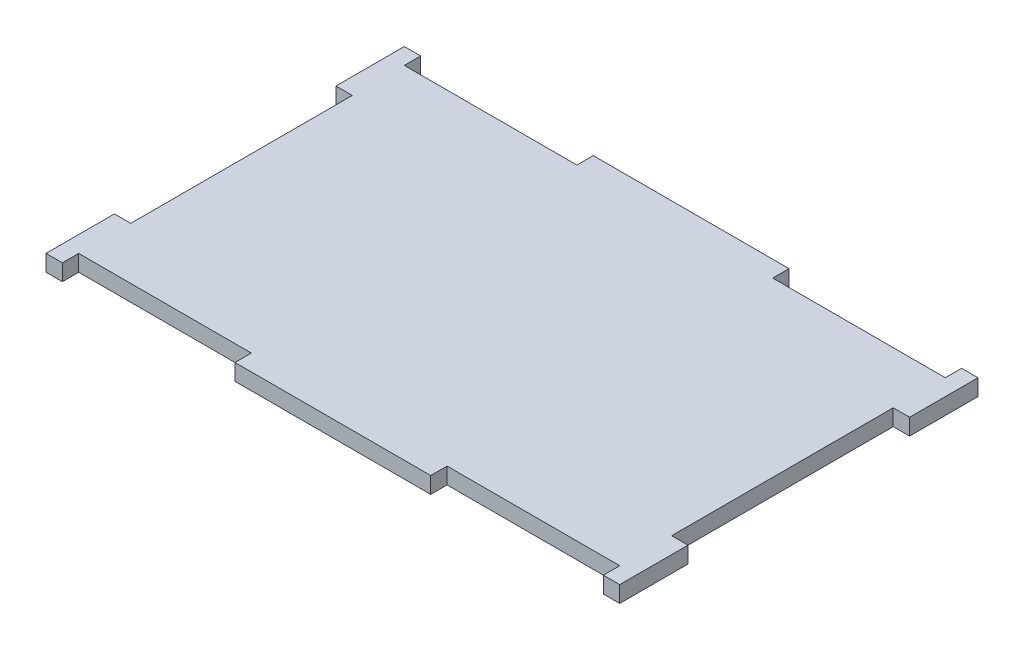
from build123d import *

# Parameters (mm, degrees)
SKETCH1_W           = 38
SKETCH1_H           = 3.175
BOSS_EXTRUDE1_DEPTH = 3.175


with BuildPart() as part:
    # Sketch1 → Boss-Extrude1 (new body)
    with BuildSketch(Plane(origin=(0, 0, 0), x_dir=(1, 0, 0), z_dir=(0, 1, 0))):
        Polygon((0, 13.275), (0, 0), (3.175, 0), (3.175, 3.175), (36.675, 3.175), (74.675, 3.175), (108.175, 3.175), (108.175, 0), (111.35, 0), (111.35, 13.275), (108.175, 13.275), (108.175, 56.275), (111.35, 56.275), (111.35, 69.55), (108.175, 69.55), (108.175, 66.375), (74.675, 66.375), (36.675, 66.375), (3.175, 66.375), (3.175, 69.55), (0, 69.55), (0, 56.275), (3.175, 56.275), (3.175, 13.275), align=None)
        with Locations((55.675, 67.9625)):
            Rectangle(SKETCH1_W, SKETCH1_H)
        with Locations((55.675, 1.5875)):
            Rectangle(SKETCH1_W, SKETCH1_H)
    extrude(amount=BOSS_EXTRUDE1_DEPTH)


solid = part.part
